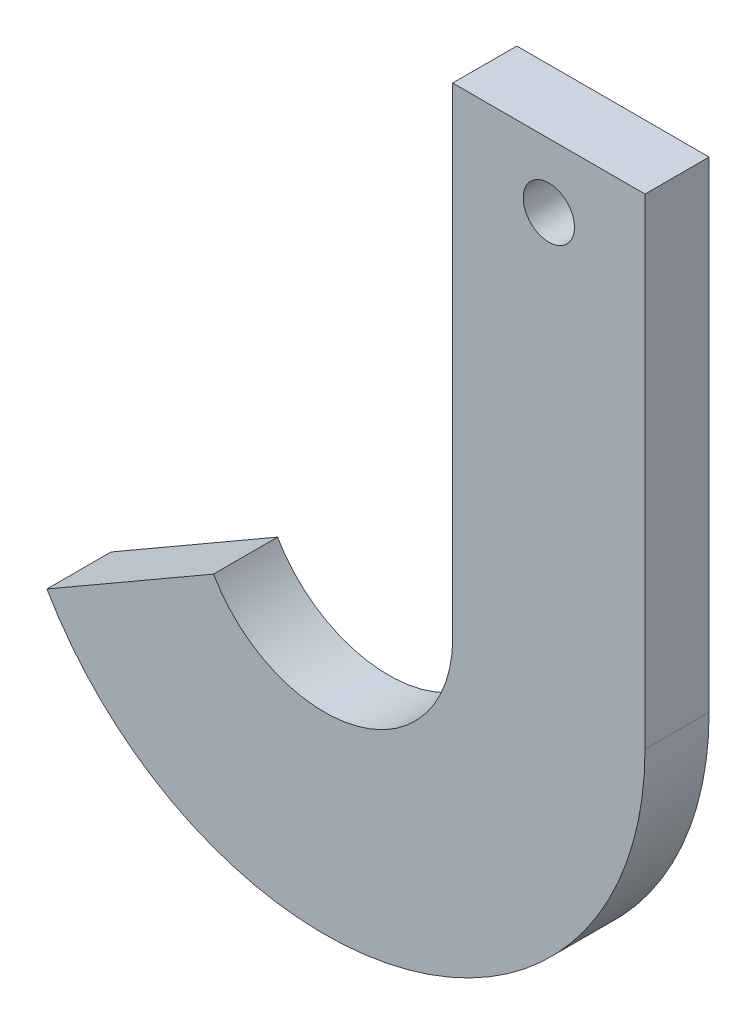
from build123d import *

# Parameters (mm, degrees)
EXTRUDE1_DEPTH = 20
SKETCH2_R      = 8
EXTRUDE3_DEPTH = 21


with BuildPart() as part:
    # Sketch1 → Extrude1 (new body)
    with BuildSketch(Plane.XY):
        with BuildLine():
            Line((-34.641016151, -20), (-86.602540378, -50))
            ThreePointArc((-86.602540378, -50), (25.88190451, -96.592582629), (100, 0))
            Line((100, 0), (100, 150))
            Line((100, 150), (40, 150))
            Line((40, 150), (40, 0))
            ThreePointArc((40, 0), (10.352761804, -38.637033052), (-34.641016151, -20))
        make_face()
    extrude(amount=EXTRUDE1_DEPTH)

    # Sketch2 → Extrude3 (cut, through all)
    with BuildSketch(Plane.XY):
        with Locations((70, 130)):
            Circle(SKETCH2_R)
    extrude(amount=EXTRUDE3_DEPTH, mode=Mode.SUBTRACT)


solid = part.part
